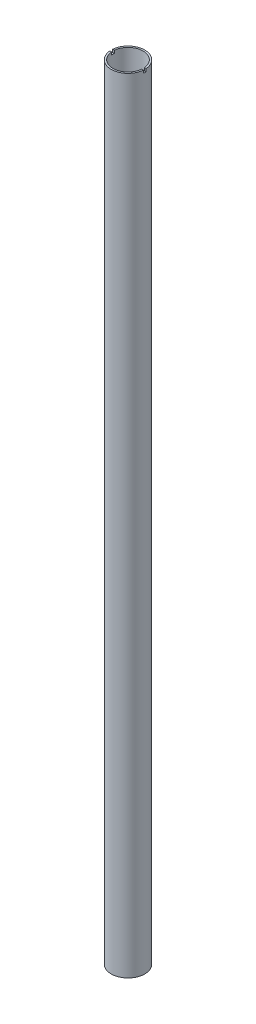
from build123d import *

# Parameters (mm, degrees)
SKETCH1_R           = 15
SKETCH1_R_2         = 13.5
BOSS_EXTRUDE1_DEPTH = 700
SKETCH2_W           = 30
SKETCH2_H           = 2.5
CUT_EXTRUDE1_DEPTH  = 2.5


with BuildPart() as part:
    # Sketch1 → Boss-Extrude1 (new body)
    with BuildSketch(Plane(origin=(0, 0, 0), x_dir=(1, 0, 0), z_dir=(0, 1, 0))):
        Circle(SKETCH1_R)
        Circle(SKETCH1_R_2, mode=Mode.SUBTRACT)
    extrude(amount=BOSS_EXTRUDE1_DEPTH)

    # Sketch2 → Cut-Extrude1 (cut)
    with BuildSketch(Plane(origin=(0, 700, 0), x_dir=(1, 0, 0), z_dir=(0, 1, 0))):
        Rectangle(SKETCH2_W, SKETCH2_H)
    extrude(amount=-CUT_EXTRUDE1_DEPTH, mode=Mode.SUBTRACT)


solid = part.part
